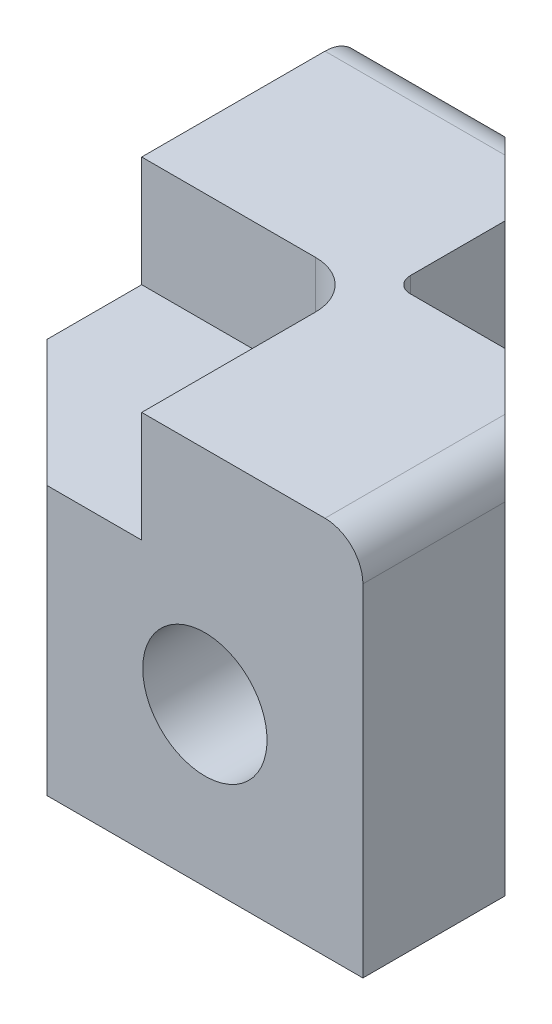
from build123d import *

# Parameters (mm, degrees)
BOSS_EXTRUDE2_DEPTH = 38.1
SKETCH24_W          = 13.462
SKETCH24_H          = 6.242787019
FILLET16_R          = 3.81
CUT_EXTRUDE3_DEPTH  = 11.1125
SKETCH101_R         = 2.54
CUT_EXTRUDE4_DEPTH  = 17.78
SKETCH102_W         = 10.16
SKETCH102_H         = 1.27
CHAMFER1_SIZE       = 12.7
FILLET17_R          = 1.5875


with BuildPart() as part:
    # Sketch7 → Boss-Extrude2 (new body)
    with BuildSketch(Plane(origin=(0, 0, 0), x_dir=(1, 0, 0), z_dir=(0, 1, 0))):
        Polygon((0, 0), (11.1125, 0), (20.6375, -9.525), (20.6375, -23.8125), (-23.8125, -23.8125), align=None)
    boss_extrude2 = extrude(amount=BOSS_EXTRUDE2_DEPTH)

    # Sketch24 → Port Manifold (revolve, cut)
    with BuildSketch(Plane.ZY.offset(-4.7625)):
        with Locations((17.0815, 18.99639351)):
            Rectangle(SKETCH24_W, SKETCH24_H)
    port_manifold = revolve(axis=Axis((4.7625, 15.875, 10.3505), (0, 0, 1)), mode=Mode.SUBTRACT)

    # Mirror6: Boss-Extrude2, Port Manifold across Plane1
    add(boss_extrude2.mirror(Plane(origin=(0, 0, 0), x_dir=(0.707106781, 0, -0.707106781), z_dir=(0.707106781, 0, 0.707106781))))
    add(port_manifold.mirror(Plane(origin=(0, 0, 0), x_dir=(0.707106781, 0, -0.707106781), z_dir=(0.707106781, 0, 0.707106781))), mode=Mode.SUBTRACT)

    # Fillet16
    fillet16_edges = [part.edges().sort_by_distance(p)[0] for p in [
        (20.6375, 38.1, 16.66875),
        (-16.66875, 38.1, -20.6375),
    ]]
    fillet(fillet16_edges, radius=FILLET16_R)

    # Sketch93 → Cut-Extrude3 (cut)
    with BuildSketch(Plane(origin=(0, 38.1, 0), x_dir=(1, 0, 0), z_dir=(0, 1, 0))):
        with BuildLine():
            Line((-23.8125, -23.8125), (-1.5875, -23.8125))
            Line((-1.5875, -23.8125), (-1.5875, -6.35))
            ThreePointArc((-1.5875, -6.35), (-2.982403955, -2.982403955), (-6.35, -1.5875))
            Line((-6.35, -1.5875), (-23.8125, -1.5875))
            Line((-23.8125, -1.5875), (-23.8125, -23.8125))
        make_face()
    extrude(amount=-CUT_EXTRUDE3_DEPTH, mode=Mode.SUBTRACT)

    # Sketch101 → Cut-Extrude4 (cut)
    with BuildSketch(Plane.XZ):
        with Locations((-9.8425, 9.8425)):
            Circle(SKETCH101_R)
    extrude(amount=-CUT_EXTRUDE4_DEPTH, mode=Mode.SUBTRACT)

    # Sketch102 → Cut-Revolve1 (revolve, cut)
    with BuildSketch(Plane(origin=(0, 15.875, 0), x_dir=(1, 0, 0), z_dir=(0, 1, 0))):
        with Locations((-5.5245, -9.9695)):
            Rectangle(SKETCH102_W, SKETCH102_H)
    cut_revolve1 = revolve(axis=Axis((-0.4445, 15.875, 9.3345), (-1, 0, 0)), mode=Mode.SUBTRACT)

    # Mirror10: Cut-Revolve1 across plane
    add(cut_revolve1.mirror(Plane(origin=(0, 0, 0), x_dir=(-0.707106781, 0, 0.707106781), z_dir=(0.707106781, 0, 0.707106781))), mode=Mode.SUBTRACT)

    # Chamfer1
    chamfer1_edges = [part.edges().sort_by_distance(p)[0] for p in [
        (-23.8125, 13.49375, 23.8125),
    ]]
    chamfer(chamfer1_edges, length=CHAMFER1_SIZE)

    # Fillet17
    fillet17_edges = [part.edges().sort_by_distance(p)[0] for p in [
        (0, 19.05, 0),
    ]]
    fillet(fillet17_edges, radius=FILLET17_R)


solid = part.part
